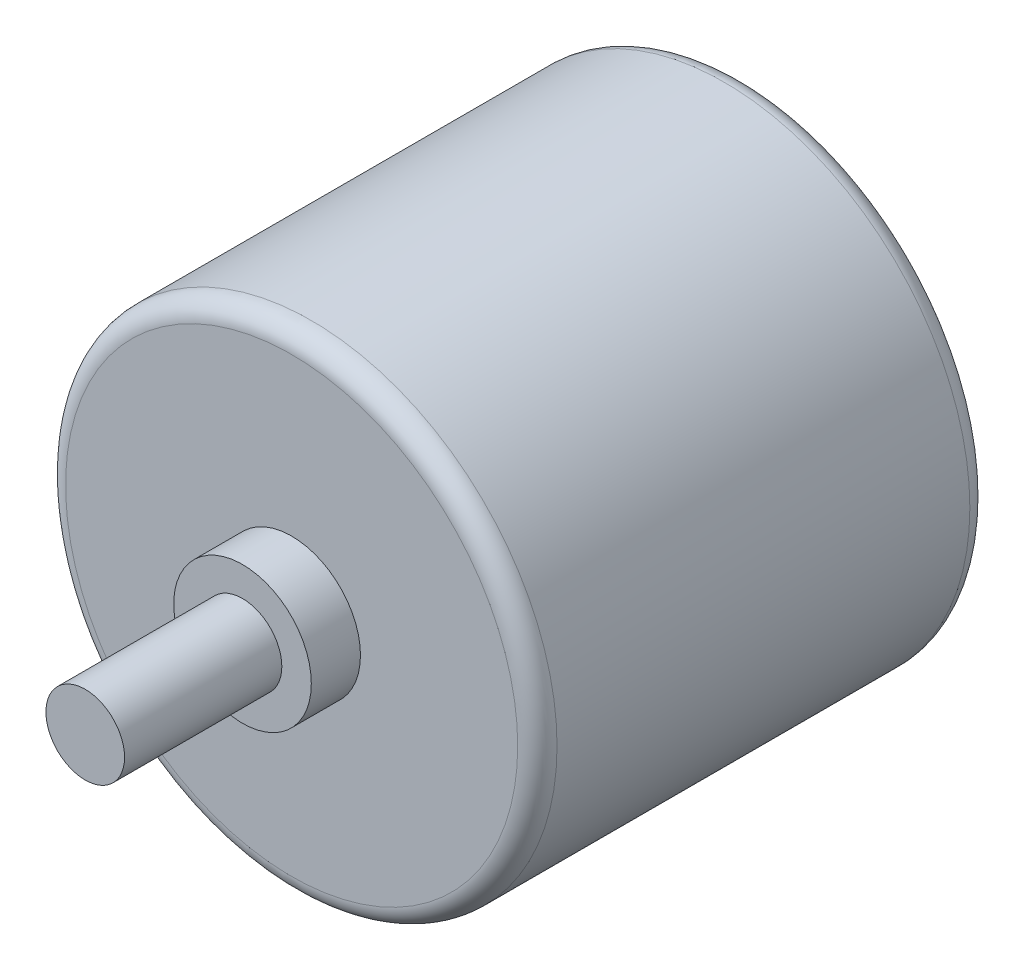
from build123d import *

# Parameters (mm, degrees)
ESBO_O1_R                = 12.5
RESSALTO_EXTRUS_O1_DEPTH = 23
ESBO_O2_R                = 3.5
RESSALTO_EXTRUS_O2_DEPTH = 2.5
FILETE1_R                = 1
ESBO_O3_R                = 2
RESSALTO_EXTRUS_O3_DEPTH = 8


with BuildPart() as part:
    # Esboço1 → Ressalto-extrusão1 (new body)
    with BuildSketch(Plane.XY):
        Circle(ESBO_O1_R)
    extrude(amount=RESSALTO_EXTRUS_O1_DEPTH)

    # Esboço2 → Ressalto-extrusão2 (add)
    with BuildSketch(Plane.XY.offset(23)):
        Circle(ESBO_O2_R)
    extrude(amount=RESSALTO_EXTRUS_O2_DEPTH)

    # Filete1
    filete1_edges = [part.edges().sort_by_distance(p)[0] for p in [
        (-12.5, 0, 0),
        (-12.5, 0, 23),
    ]]
    fillet(filete1_edges, radius=FILETE1_R)

    # Esboço3 → Ressalto-extrusão3 (add)
    with BuildSketch(Plane.XY.offset(25.5)):
        Circle(ESBO_O3_R)
    extrude(amount=RESSALTO_EXTRUS_O3_DEPTH)


solid = part.part
